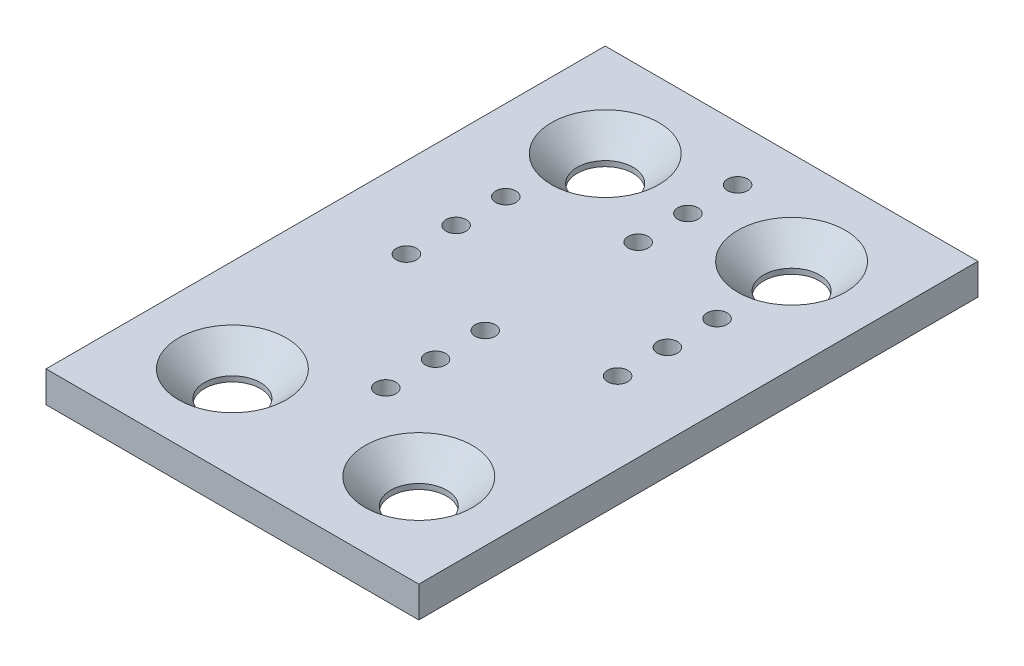
from build123d import *

# Parameters (mm, degrees)
SKETCH2_W                                    = 60
SKETCH2_H                                    = 90
SKETCH2_R                                    = 1.625
BOSS_EXTRUDE1_DEPTH                          = 5
SKETCH3_R                                    = 3.375
CUT_EXTRUDE1_DEPTH                           = 5
CSK_FOR_M8_COUNTERSUNK_FLAT_HEAD_SCR_2_COUNT = 2
CSK_FOR_M8_COUNTERSUNK_FLAT_HEAD_SCR_2_PITCH = 30
CSK_FOR_M8_COUNTERSUNK_FLAT_HEAD_SCR_3_COUNT = 2
CSK_FOR_M8_COUNTERSUNK_FLAT_HEAD_SCR_3_PITCH = 60
CSK_FOR_M8_COUNTERSUNK_FLAT_HEAD_SCR_4_COUNT = 2
CSK_FOR_M8_COUNTERSUNK_FLAT_HEAD_SCR_4_PITCH = 67.082039325


with BuildPart() as part:
    # Sketch2 → Boss-Extrude1 (new body)
    with BuildSketch(Plane(origin=(0, 0, 0), x_dir=(1, 0, 0), z_dir=(0, 1, 0))):
        Rectangle(SKETCH2_W, SKETCH2_H)
        with Locations((0, 20.309068759)):
            Circle(SKETCH2_R, mode=Mode.SUBTRACT)
        with Locations((0, -20.309068759)):
            Circle(SKETCH2_R, mode=Mode.SUBTRACT)
        with Locations((17, 0)):
            Circle(SKETCH2_R, mode=Mode.SUBTRACT)
        with Locations((-17, 0)):
            Circle(SKETCH2_R, mode=Mode.SUBTRACT)
        with Locations((0, 28.309068759)):
            Circle(SKETCH2_R, mode=Mode.SUBTRACT)
        with Locations((17, 8)):
            Circle(SKETCH2_R, mode=Mode.SUBTRACT)
        with Locations((-17, 8)):
            Circle(SKETCH2_R, mode=Mode.SUBTRACT)
        with Locations((0, -12.309068759)):
            Circle(SKETCH2_R, mode=Mode.SUBTRACT)
        with Locations((0, 36.309068759)):
            Circle(SKETCH2_R, mode=Mode.SUBTRACT)
        with Locations((17, 16)):
            Circle(SKETCH2_R, mode=Mode.SUBTRACT)
        with Locations((-17, 16)):
            Circle(SKETCH2_R, mode=Mode.SUBTRACT)
        with Locations((0, -4.309068759)):
            Circle(SKETCH2_R, mode=Mode.SUBTRACT)
    extrude(amount=BOSS_EXTRUDE1_DEPTH)

    # Sketch3 → Cut-Extrude1 (cut)
    with BuildSketch(Plane(origin=(0, 5, 0), x_dir=(1, 0, 0), z_dir=(0, 1, 0))):
        with Locations((-15, 30)):
            Circle(SKETCH3_R)
        with Locations((15, 30)):
            Circle(SKETCH3_R)
        with Locations((15, -30)):
            Circle(SKETCH3_R)
        with Locations((-15, -30)):
            Circle(SKETCH3_R)
    extrude(amount=-CUT_EXTRUDE1_DEPTH, mode=Mode.SUBTRACT)

    # Sketch4 → CSK for M8 Countersunk Flat Head Screw1 (revolve, cut)
    with BuildSketch(Plane(origin=(-15, 5, 30), x_dir=(0, 0, 1), z_dir=(1, 0, 0))):
        Polygon((0, 0), (0, 5), (4.5, 5), (4.5, 4.15), (8.65, 0), align=None)
    csk_for_m8_countersunk_flat_head_screw1 = revolve(axis=Axis((-15, 11.35, 30), (0, -1, 0)), mode=Mode.SUBTRACT)

    # CSK for M8 Countersunk Flat Head Scr 2: CSK for M8 Countersunk Flat Head Screw1 ×2
    with Locations(*[(i * CSK_FOR_M8_COUNTERSUNK_FLAT_HEAD_SCR_2_PITCH, 0, 0) for i in range(1, CSK_FOR_M8_COUNTERSUNK_FLAT_HEAD_SCR_2_COUNT)]):
        add(csk_for_m8_countersunk_flat_head_screw1, mode=Mode.SUBTRACT)

    # CSK for M8 Countersunk Flat Head Scr 3: CSK for M8 Countersunk Flat Head Screw1 ×2
    with Locations(*[(0, 0, -i * CSK_FOR_M8_COUNTERSUNK_FLAT_HEAD_SCR_3_PITCH) for i in range(1, CSK_FOR_M8_COUNTERSUNK_FLAT_HEAD_SCR_3_COUNT)]):
        add(csk_for_m8_countersunk_flat_head_screw1, mode=Mode.SUBTRACT)

    # CSK for M8 Countersunk Flat Head Scr 4: CSK for M8 Countersunk Flat Head Screw1 ×2
    with Locations(*[Vector(0.447213595, 0, -0.894427191) * (i * CSK_FOR_M8_COUNTERSUNK_FLAT_HEAD_SCR_4_PITCH) for i in range(1, CSK_FOR_M8_COUNTERSUNK_FLAT_HEAD_SCR_4_COUNT)]):
        add(csk_for_m8_countersunk_flat_head_screw1, mode=Mode.SUBTRACT)


solid = part.part
